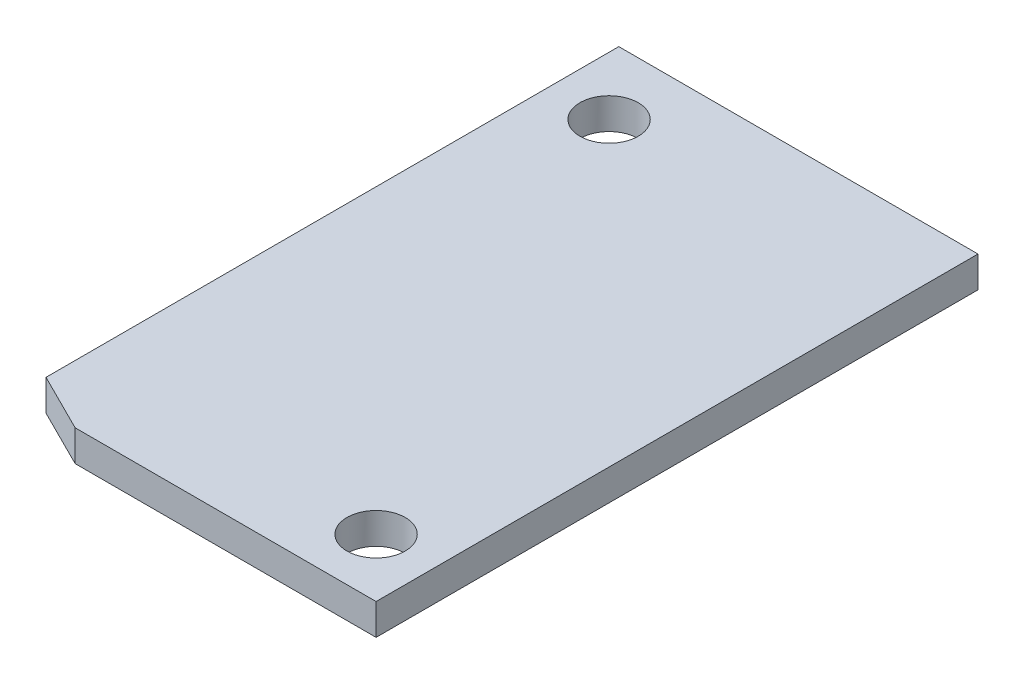
from build123d import *

# Parameters (mm, degrees)
EXTRUDE1_DEPTH               = 1.6
F_3_0_3_DIAMETER_HOLE1_D     = 3
F_3_0_3_DIAMETER_HOLE1_DEPTH = 10
F_3_0_3_DIAMETER_HOLE1_TIP   = 0.901290929


with BuildPart() as part:
    # Sketch1 → Extrude1 (new body)
    with BuildSketch(Plane(origin=(0, 0, 0), x_dir=(1, 0, 0), z_dir=(0, 1, 0))):
        Polygon((-6.25, -15.5), (9.25, -15.5), (9.25, 15.5), (-9.25, 15.5), (-9.25, -14), align=None)
    extrude(amount=EXTRUDE1_DEPTH)

    # Ø3.0 (3) Diameter Hole1
    with Locations(Plane(origin=(6.25, 1.6, 12.5), x_dir=(0, 0, 1), z_dir=(0, 1, 0))):
        with Locations((0, 0), (-24.5, -12.5)):
            Hole(F_3_0_3_DIAMETER_HOLE1_D / 2, depth=F_3_0_3_DIAMETER_HOLE1_DEPTH)
            with Locations((0, 0, -(F_3_0_3_DIAMETER_HOLE1_DEPTH + F_3_0_3_DIAMETER_HOLE1_TIP / 2))):  # 118° drill point
                Cone(0, F_3_0_3_DIAMETER_HOLE1_D / 2, F_3_0_3_DIAMETER_HOLE1_TIP, mode=Mode.SUBTRACT)


solid = part.part
